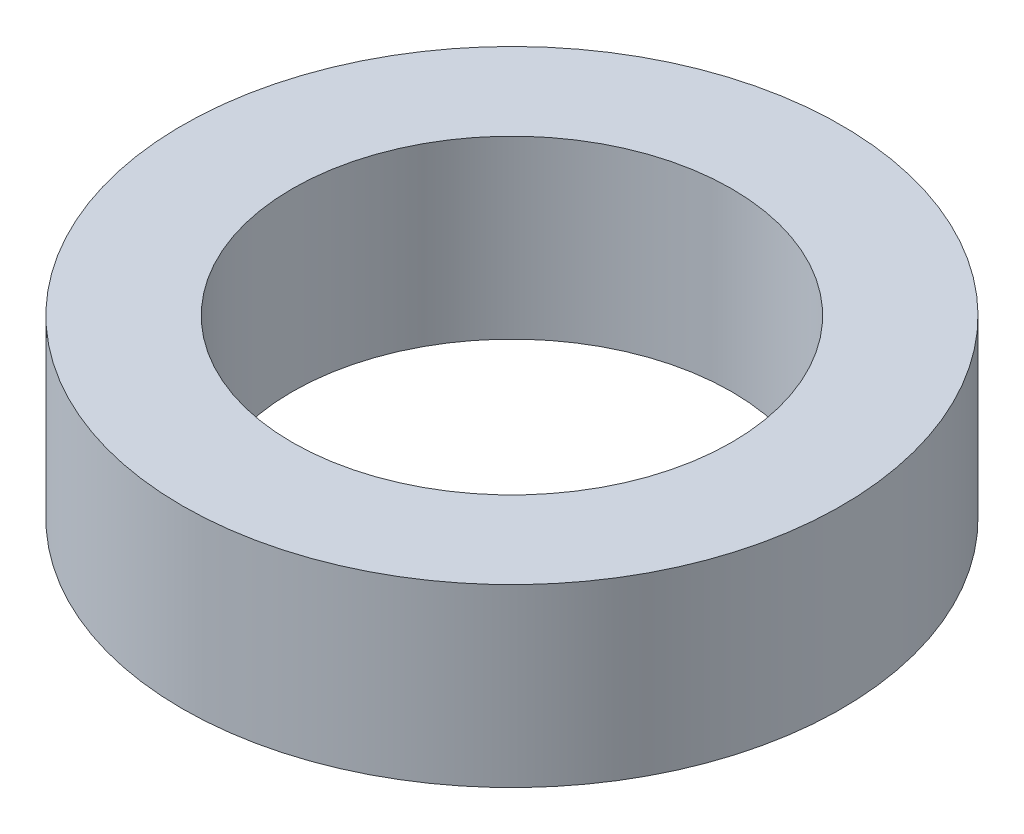
from build123d import *

# Parameters (mm, degrees)
SKETCH_1_R      = 7.5
SKETCH_1_R_2    = 5
EXTRUDE_1_DEPTH = 4


with BuildPart() as part:
    # 草图1 → 凸台-拉伸1 (new body)
    with BuildSketch(Plane(origin=(0, 0, 0), x_dir=(1, 0, 0), z_dir=(0, 1, 0))):
        Circle(SKETCH_1_R)
        Circle(SKETCH_1_R_2, mode=Mode.SUBTRACT)
    extrude(amount=EXTRUDE_1_DEPTH)


solid = part.part
